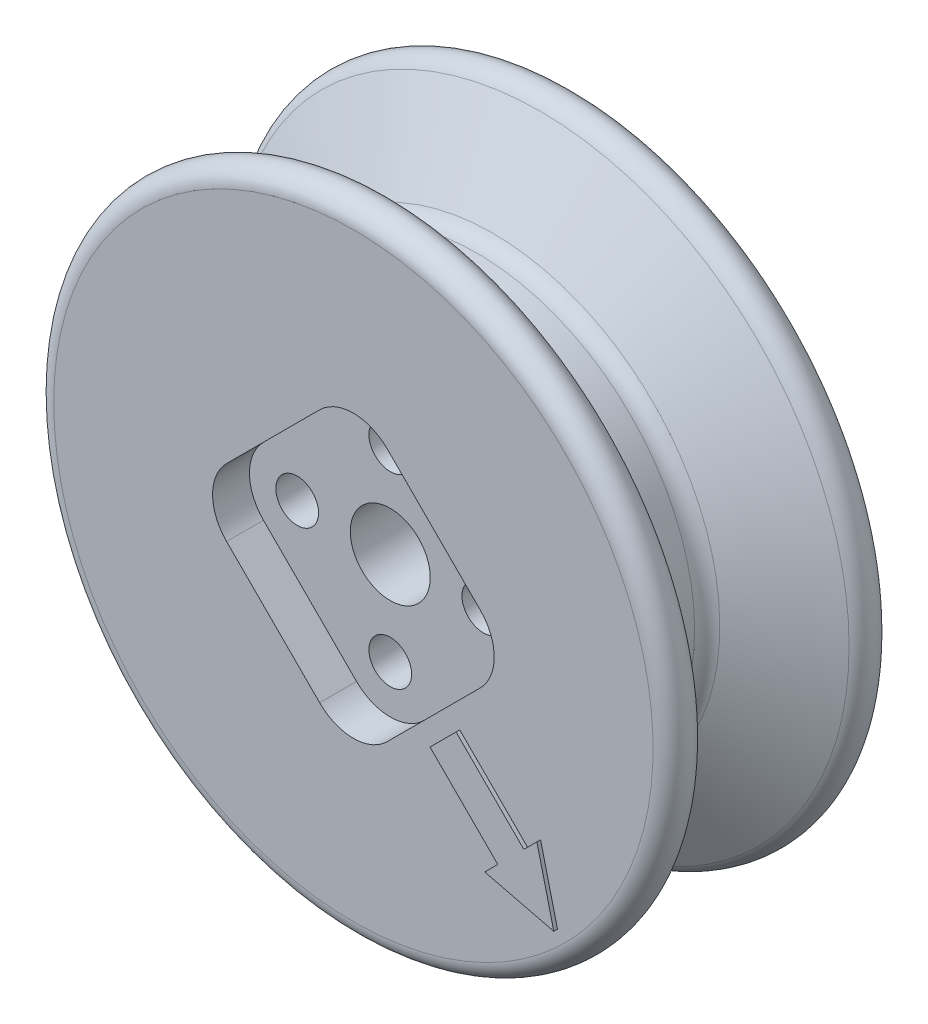
from build123d import *

# Parameters (mm, degrees)
SKETCH1_R           = 9.525
SKETCH1_R_2         = 2.754
SKETCH1_R_3         = 1.4732
BOSS_EXTRUDE1_DEPTH = 10.16
SKETCH4_R           = 3.0353
CUT_EXTRUDE1_DEPTH  = 5.08
CUT_EXTRUDE2_REACH  = 47.124
SKETCH4_3_R         = 1.397
CUT_EXTRUDE3_DEPTH  = 34.498522471
BOSS_EXTRUDE2_DEPTH = 0.254


with BuildPart() as part:
    # Sketch1 → Boss-Extrude1 (new body)
    with BuildSketch(Plane.XY):
        Circle(SKETCH1_R)
        Circle(SKETCH1_R_2, mode=Mode.SUBTRACT)
        with Locations((0, 6.413072646)):
            Circle(SKETCH1_R_3, mode=Mode.SUBTRACT)
        with Locations((6.413072646, 0)):
            Circle(SKETCH1_R_3, mode=Mode.SUBTRACT)
        with Locations((0, -6.413072646)):
            Circle(SKETCH1_R_3, mode=Mode.SUBTRACT)
        with Locations((-6.413072646, 0)):
            Circle(SKETCH1_R_3, mode=Mode.SUBTRACT)
    extrude(amount=BOSS_EXTRUDE1_DEPTH)

    # Sketch2 → Revolve1 (revolve)
    with BuildSketch(Plane(origin=(0, 0, 0), x_dir=(1, 0, 0), z_dir=(0, 1, 0))):
        with BuildLine():
            Line((14.9999954, -3.429), (14.9999954, -1.651))
            ThreePointArc((14.9999954, -1.651), (15.170143137, -1.016), (15.6349954, -0.551147737))
            Line((15.6349954, -0.551147737), (21.28372486, 2.710147737))
            ThreePointArc((21.28372486, 2.710147737), (21.87545066, 4.138700187), (20.64872486, 5.08))
            Line((20.64872486, 5.08), (9.906, 5.08))
            Line((9.906, 5.08), (9.906, 0))
            Line((9.906, 0), (9.525, 0))
            Line((9.525, 0), (9.525, -10.16))
            Line((9.525, -10.16), (20.64872486, -10.16))
            ThreePointArc((20.64872486, -10.16), (21.87545066, -9.218700187), (21.28372486, -7.790147737))
            Line((21.28372486, -7.790147737), (15.6349954, -4.528852263))
            ThreePointArc((15.6349954, -4.528852263), (15.170143137, -4.064), (14.9999954, -3.429))
        make_face()
    revolve(axis=Axis((0, 0, -5.08), (0, 0, 1)))

    # Sketch4 → Cut-Extrude1 (cut)
    with BuildSketch(Plane(origin=(9.169757486, -9.169757486, 0), x_dir=(0, 0, 1), z_dir=(-0.7071067811865487, 0.7071067811865464, 0))):
        with Locations((2.54, 0)):
            Circle(SKETCH4_R)
    extrude(amount=-CUT_EXTRUDE1_DEPTH, mode=Mode.SUBTRACT)

    # Sketch4_3 → Cut-Extrude2 (cut, up to next)
    with BuildSketch(Plane(origin=(9.169757486, -9.169757486, 0), x_dir=(0, 0, 1), z_dir=(-0.7071067811865487, 0.7071067811865464, 0)), mode=Mode.PRIVATE) as cut_extrude2_sk1:
        with Locations((2.54, 0)):
            Circle(SKETCH4_3_R)
    cut_extrude2_tool1 = extrude(cut_extrude2_sk1.sketch, amount=CUT_EXTRUDE2_REACH, mode=Mode.PRIVATE) & part.part
    add(cut_extrude2_tool1.solids().sort_by_distance((9.169757, -9.169757, 2.54))[0], mode=Mode.SUBTRACT)

    # Sketch5 → Cut-Extrude3 (cut, through all)
    with BuildSketch(Plane(origin=(0, 0, 7.62), x_dir=(-1, 0, 0), z_dir=(0, 0, -1))):
        with BuildLine():
            Line((8.738958982, 2.325886335), (2.325886335, 8.738958982))
            ThreePointArc((2.325886335, 8.738958982), (0, 9.702372646), (-2.325886335, 8.738958982))
            Line((-2.325886335, 8.738958982), (-8.738958982, 2.325886335))
            ThreePointArc((-8.738958982, 2.325886335), (-9.702372646, 0), (-8.738958982, -2.325886335))
            Line((-8.738958982, -2.325886335), (-2.325886335, -8.738958982))
            ThreePointArc((-2.325886335, -8.738958982), (0, -9.702372646), (2.325886335, -8.738958982))
            Line((2.325886335, -8.738958982), (8.738958982, -2.325886335))
            ThreePointArc((8.738958982, -2.325886335), (9.702372646, 0), (8.738958982, 2.325886335))
        make_face()
    extrude(amount=-CUT_EXTRUDE3_DEPTH, mode=Mode.SUBTRACT)

    # Sketch6 → Boss-Extrude2 (add)
    with BuildSketch(Plane.XY.offset(10.16)):
        Polygon((5.532422659, -7.328473883), (7.328473883, -5.532422659), (11.998207066, -10.202155842), (12.896232678, -9.304130229), (14.062038004, -14.062038004), (9.304130229, -12.896232678), (10.202155842, -11.998207066), align=None)
    extrude(amount=BOSS_EXTRUDE2_DEPTH)


solid = part.part
